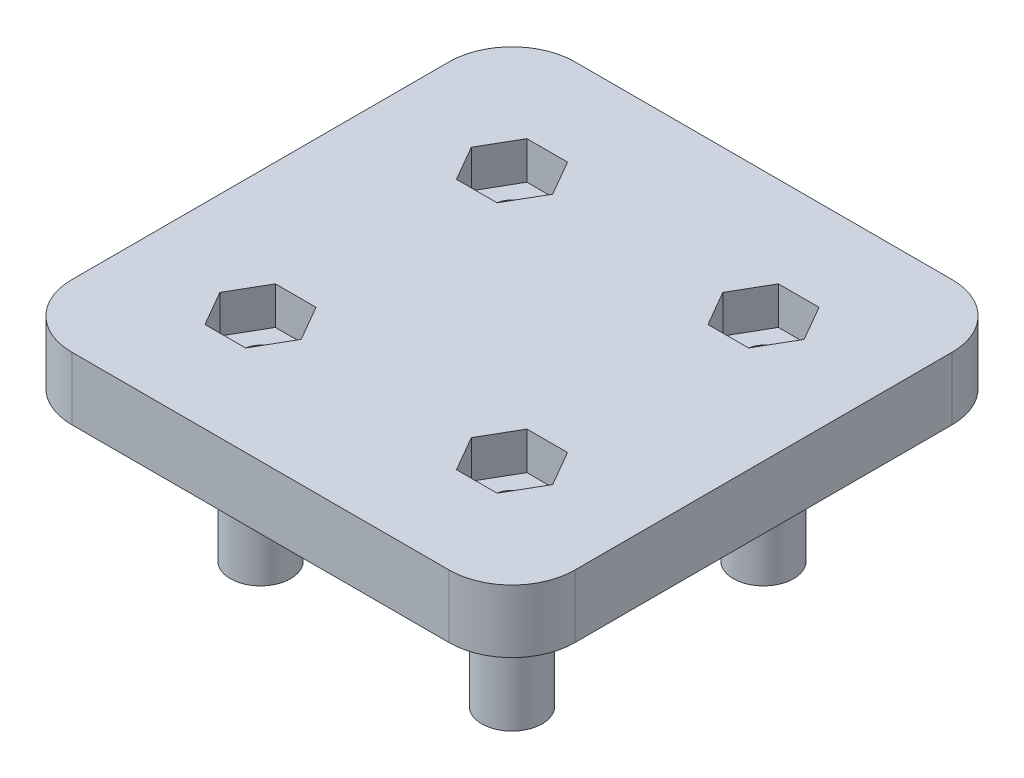
from build123d import *

# Parameters (mm, degrees)
SKETCH1_W           = 40
SKETCH1_H           = 40
BOSS_EXTRUDE1_DEPTH = 5
CUT_EXTRUDE1_DEPTH  = 3
SKETCH3_R           = 1.4
CUT_EXTRUDE2_DEPTH  = 29.442925307
FILLET1_R           = 5
SKETCH3_3_R         = 2.4
SKETCH3_3_R_2       = 1.4
BOSS_EXTRUDE2_DEPTH = 13.9


with BuildPart() as part:
    # Sketch1 → Boss-Extrude1 (new body)
    with BuildSketch(Plane(origin=(0, 0, 0), x_dir=(1, 0, 0), z_dir=(0, 1, 0))):
        Rectangle(SKETCH1_W, SKETCH1_H)
    extrude(amount=BOSS_EXTRUDE1_DEPTH)

    # Sketch2 → Cut-Extrude1 (cut)
    with BuildSketch(Plane(origin=(0, 5, 0), x_dir=(1, 0, 0), z_dir=(0, 1, 0))):
        Polygon((-8.383419246, -7.2), (-11.616580754, -7.2), (-13.233161507, -10), (-11.616580754, -12.8), (-8.383419246, -12.8), (-6.766838493, -10), align=None)
        Polygon((8.383419246, -7.2), (6.766838493, -10), (8.383419246, -12.8), (11.616580754, -12.8), (13.233161507, -10), (11.616580754, -7.2), align=None)
        Polygon((-11.616580754, 7.2), (-8.383419246, 7.2), (-6.766838493, 10), (-8.383419246, 12.8), (-11.616580754, 12.8), (-13.233161507, 10), align=None)
        Polygon((8.383419246, 7.2), (11.616580754, 7.2), (13.233161507, 10), (11.616580754, 12.8), (8.383419246, 12.8), (6.766838493, 10), align=None)
    extrude(amount=-CUT_EXTRUDE1_DEPTH, mode=Mode.SUBTRACT)

    # Sketch3 → Cut-Extrude2 (cut, through all)
    with BuildSketch(Plane(origin=(0, 2, 0), x_dir=(1, 0, 0), z_dir=(0, 1, 0))):
        with Locations((-10, 10)):
            Circle(SKETCH3_R)
        with Locations((10, 10)):
            Circle(SKETCH3_R)
        with Locations((-10, -10)):
            Circle(SKETCH3_R)
        with Locations((10, -10)):
            Circle(SKETCH3_R)
    extrude(amount=-CUT_EXTRUDE2_DEPTH, mode=Mode.SUBTRACT)

    # Fillet1
    fillet1_edges = [part.edges().sort_by_distance(p)[0] for p in [
        (-20, 2.5, 20),
        (20, 2.5, 20),
        (20, 2.5, -20),
        (-20, 2.5, -20),
    ]]
    fillet(fillet1_edges, radius=FILLET1_R)

    # Sketch3_3 → Boss-Extrude2 (add)
    # profile 1 of 4: a face of its own
    with BuildSketch(Plane(origin=(0, 2, 0), x_dir=(1, 0, 0), z_dir=(0, 1, 0))):
        with Locations((-10, 10)):
            Circle(SKETCH3_3_R)
        with Locations((-10, 10)):
            Circle(SKETCH3_3_R_2, mode=Mode.SUBTRACT)
    # profile 2 of 4: a face of its own
    with BuildSketch(Plane(origin=(0, 2, 0), x_dir=(1, 0, 0), z_dir=(0, 1, 0))):
        with Locations((-10, -10)):
            Circle(SKETCH3_3_R)
        with Locations((-10, -10)):
            Circle(SKETCH3_3_R_2, mode=Mode.SUBTRACT)
    # profile 3 of 4: a face of its own
    with BuildSketch(Plane(origin=(0, 2, 0), x_dir=(1, 0, 0), z_dir=(0, 1, 0))):
        with Locations((10, -10)):
            Circle(SKETCH3_3_R)
        with Locations((10, -10)):
            Circle(SKETCH3_3_R_2, mode=Mode.SUBTRACT)
    # profile 4 of 4: a face of its own
    with BuildSketch(Plane(origin=(0, 2, 0), x_dir=(1, 0, 0), z_dir=(0, 1, 0))):
        with Locations((10, 10)):
            Circle(SKETCH3_3_R)
        with Locations((10, 10)):
            Circle(SKETCH3_3_R_2, mode=Mode.SUBTRACT)
    extrude(amount=-BOSS_EXTRUDE2_DEPTH)


solid = part.part
